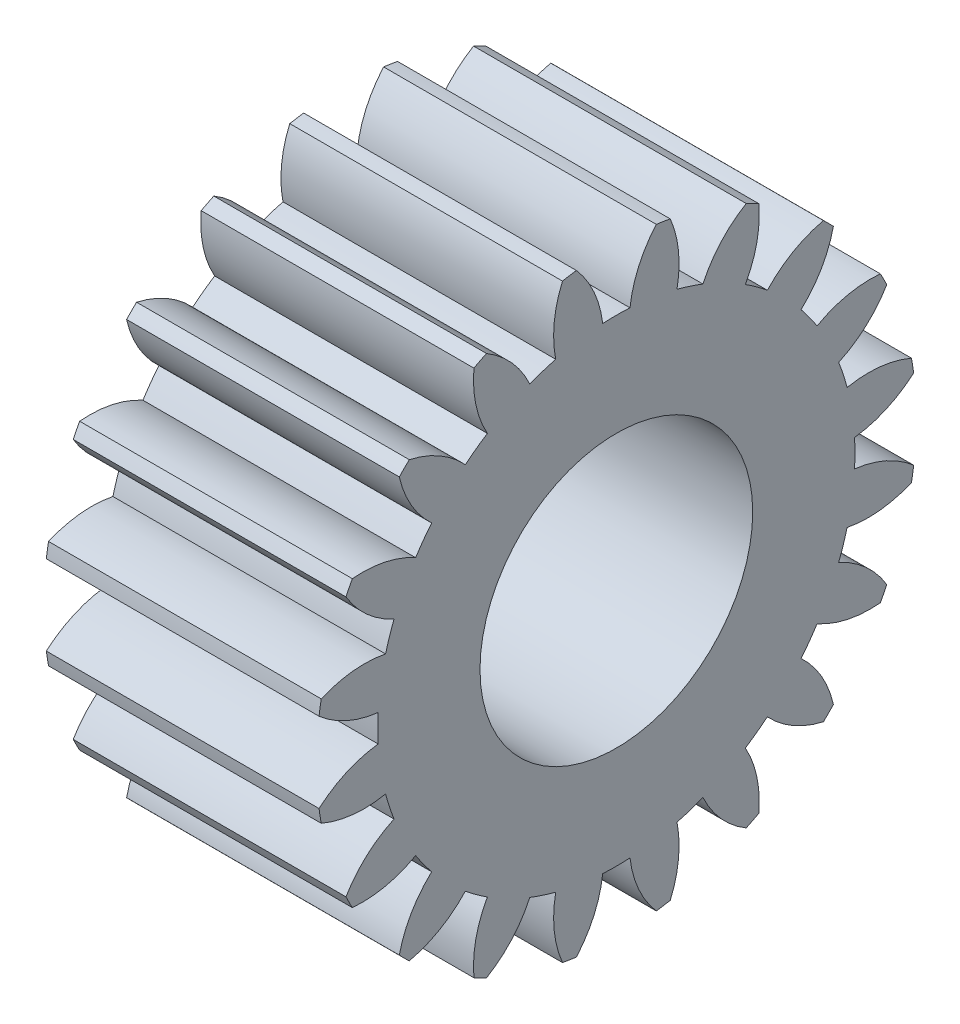
from build123d import *

# Parameters (mm, degrees)
BASPROSKE_W     = 10
BASPROSKE_H     = 11
TOOTHCUT_DEPTH  = 19.493242009
TEETHCUTS_COUNT = 20
TEETHCUTS_ANGLE = 342
BORSKE_R        = 5
BORE_DEPTH      = 50.0000508


with BuildPart() as part:
    # BasProSke → Base-Revolve (revolve)
    with BuildSketch(Plane(origin=(0, 0, 0), x_dir=(1, 0, 0), z_dir=(0, 1, 0)), mode=Mode.PRIVATE) as base_revolve_sk:
        with Locations((5, 5.5)):
            Rectangle(BASPROSKE_W, BASPROSKE_H)
    revolve(base_revolve_sk.sketch.rotate(Axis((-10, 0, 0), (1, 0, 0)), 180), axis=Axis((-10, 0, 0), (1, 0, 0)))

    # TooCutSke → ToothCut (cut, through all)
    with BuildSketch(Plane(origin=(0, 0, 0), x_dir=(0, 0, -1), z_dir=(1, 0, 0))):
        with BuildLine():
            ThreePointArc((0.499924007, 8.734705318), (0, 8.749), (-0.499924007, 8.734705318))
            ThreePointArc((-0.499924007, 8.734705318), (-0.824302243, 9.905497836), (-1.485192705, 10.924909509))
            ThreePointArc((-1.485192705, 10.924909509), (0, 11.0254), (1.485192705, 10.924909509))
            ThreePointArc((1.485192705, 10.924909509), (0.824302243, 9.905497836), (0.499924007, 8.734705318))
        make_face()
    toothcut = extrude(amount=TOOTHCUT_DEPTH, mode=Mode.SUBTRACT)

    # TeethCuts: ToothCut ×20 about axis
    teethcuts_axis = Axis((-10, 0, 0), (1, 0, 0))
    for i in range(1, TEETHCUTS_COUNT):
        add(toothcut.rotate(teethcuts_axis, i * TEETHCUTS_ANGLE / (TEETHCUTS_COUNT - 1)), mode=Mode.SUBTRACT)

    # BorSke → Bore (cut, symmetric)
    with BuildSketch(Plane(origin=(0, 0, 0), x_dir=(0, 0, -1), z_dir=(1, 0, 0))):
        with Locations(Location((0, 0, 0), (0, 0, 180))):
            Circle(BORSKE_R)
    extrude(amount=BORE_DEPTH, both=True, mode=Mode.SUBTRACT)


solid = part.part
